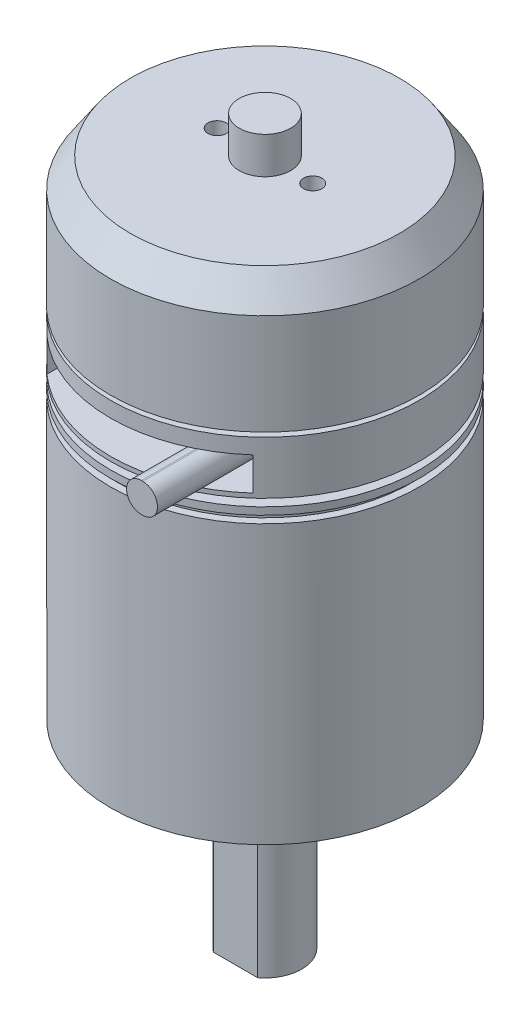
from build123d import *

# Parameters (mm, degrees)
SKETCH_2_W             = 28
SKETCH_2_H             = 4.5
CUT_EXTRUDE_1_DEPTH    = 10
EXTRUDE_1_DEPTH        = 15
HOLE_WIZARD_M3_1_D     = 2.5
HOLE_WIZARD_M3_1_DEPTH = 4
HOLE_WIZARD_M3_1_TIP   = 0.751075774
CUT_EXTRUDE_2_DEPTH    = 20
HOLE_WIZARD_M4_1_D     = 3.3
HOLE_WIZARD_M4_1_DEPTH = 10.1
HOLE_WIZARD_M4_1_TIP   = 0.991420021


with BuildPart() as part:
    # 草图1 → 旋转1 (revolve)
    with BuildSketch(Plane.XY):
        Polygon((0, 0), (4.1, 0), (4.1, 6.7), (13.4, 6.7), (13.4, 8.7), (21, 8.7), (21, 10.2), (20, 10.2), (20, 11.2), (21, 11.2), (21, 12.2), (10, 12.2), (10, 13.2), (21, 13.2), (21, 20.4), (5, 20.4), (5, 21), (21, 21), (21, 34.7), (18.3, 38.7), (3.5, 38.7), (3.5, 43.7), (0, 43.7), align=None)
    revolve(axis=Axis((0, 43.7, 0), (0, -1, 0)))

    # 草图2 → 切除-拉伸1 (cut)
    with BuildSketch(Plane.XY.offset(21)):
        with Locations((0, 16.05)):
            Rectangle(SKETCH_2_W, SKETCH_2_H)
    extrude(amount=-CUT_EXTRUDE_1_DEPTH, mode=Mode.SUBTRACT)

    # 草图3 → 凸台-拉伸1 (add)
    with BuildSketch(Plane.XY.offset(11)):
        with BuildLine():
            Line((9.185056323, 18.053194417), (9.385056323, 18.053194417))
            ThreePointArc((9.385056323, 18.053194417), (11.385056323, 16.053194417), (9.385056323, 14.053194417))
            Line((9.385056323, 14.053194417), (9.185056323, 14.053194417))
            ThreePointArc((9.185056323, 14.053194417), (7.185056323, 16.053194417), (9.185056323, 18.053194417))
        make_face()
    extrude(amount=EXTRUDE_1_DEPTH)

    # M3 螺纹孔1
    with Locations(Plane(origin=(0, 38.7, 0), x_dir=(1, 0, 0), z_dir=(0, 1, 0))):
        with Locations((-6.5, 0), (6.5, 0)):
            Hole(HOLE_WIZARD_M3_1_D / 2, depth=HOLE_WIZARD_M3_1_DEPTH)
            with Locations((0, 0, -(HOLE_WIZARD_M3_1_DEPTH + HOLE_WIZARD_M3_1_TIP / 2))):  # 118° drill point
                Cone(0, HOLE_WIZARD_M3_1_D / 2, HOLE_WIZARD_M3_1_TIP, mode=Mode.SUBTRACT)

    # 草图7 → 旋转2 (revolve)
    with BuildSketch(Plane.XY):
        Polygon((0, -54.6), (5, -54.6), (5, -30.5), (8.275, -30.5), (8.275, -29.6), (13, -29.6), (13, -27.6), (21, -27.6), (21, 8.7), (0, 8.7), align=None)
    revolve(axis=Axis((0, 8.7, 0), (0, -1, 0)))

    # 草图8 → 切除-拉伸2 (cut)
    with BuildSketch(Plane.XZ.offset(54.6)):
        with BuildLine():
            Line((-3, 4), (3, 4))
            ThreePointArc((3, 4), (0, 5), (-3, 4))
        make_face()
    extrude(amount=-CUT_EXTRUDE_2_DEPTH, mode=Mode.SUBTRACT)

    # M4 螺纹孔1
    with Locations(Plane(origin=(0, -27.6, 0), x_dir=(-1, 0, 0), z_dir=(0, -1, 0))):
        with Locations((0, -17.5), (-17.5, 0), (0, 17.5), (17.5, 0)):
            Hole(HOLE_WIZARD_M4_1_D / 2, depth=HOLE_WIZARD_M4_1_DEPTH)
            with Locations((0, 0, -(HOLE_WIZARD_M4_1_DEPTH + HOLE_WIZARD_M4_1_TIP / 2))):  # 118° drill point
                Cone(0, HOLE_WIZARD_M4_1_D / 2, HOLE_WIZARD_M4_1_TIP, mode=Mode.SUBTRACT)


solid = part.part
